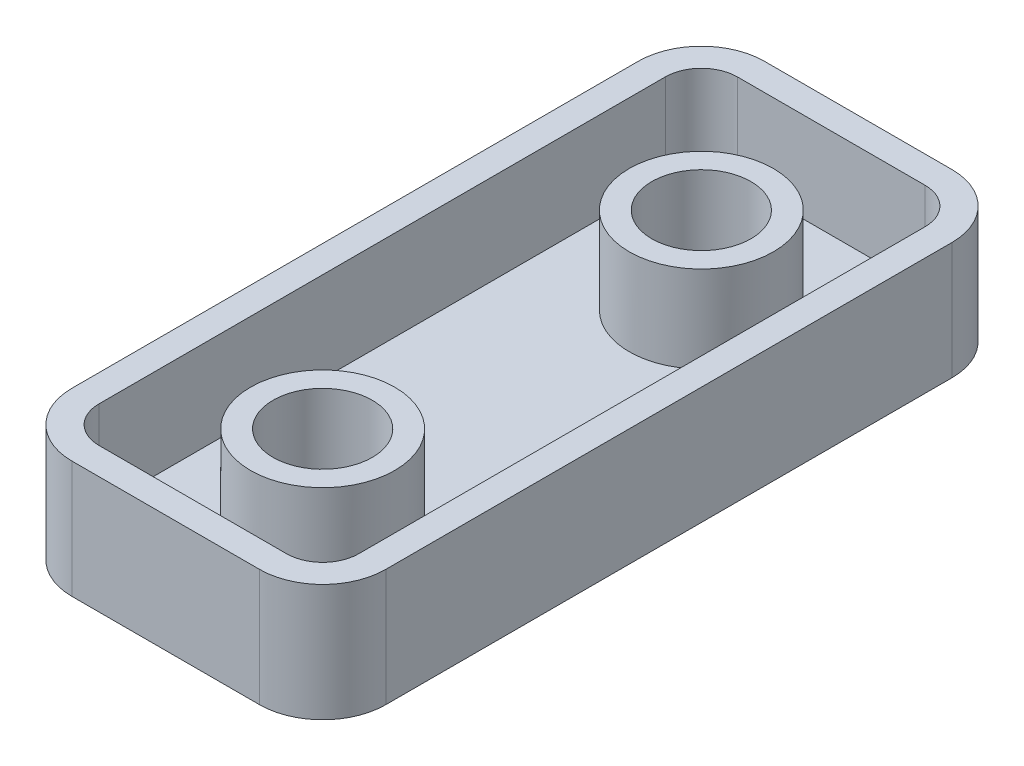
from build123d import *

# Parameters (mm, degrees)
SKETCH1_W           = 17.4
SKETCH1_H           = 38.4
BOSS_EXTRUDE1_DEPTH = 6.5
FILLET1_R           = 3.5
CUT_EXTRUDE1_DEPTH  = 5
SKETCH3_R           = 4
SKETCH3_R_2         = 2.75
BOSS_EXTRUDE2_DEPTH = 4.8
SKETCH4_R           = 2.75
CUT_EXTRUDE2_DEPTH  = 0.9


with BuildPart() as part:
    # Sketch1 → Boss-Extrude1 (new body)
    with BuildSketch(Plane(origin=(0, 0, 0), x_dir=(1, 0, 0), z_dir=(0, 1, 0))):
        with Locations((-8.7, -19.2)):
            Rectangle(SKETCH1_W, SKETCH1_H)
    extrude(amount=BOSS_EXTRUDE1_DEPTH)

    # Fillet1
    fillet1_edges = [part.edges().sort_by_distance(p)[0] for p in [
        (0, 3.25, 38.4),
        (-17.4, 3.25, 38.4),
        (-17.4, 3.25, 0),
        (0, 3.25, 0),
    ]]
    fillet(fillet1_edges, radius=FILLET1_R)

    # Sketch2 → Cut-Extrude1 (cut)
    with BuildSketch(Plane(origin=(0, 6.5, 0), x_dir=(1, 0, 0), z_dir=(0, 1, 0))):
        with BuildLine():
            Line((-13.9, -36.9), (-3.5, -36.9))
            ThreePointArc((-3.5, -36.9), (-2.085786438, -36.314213562), (-1.5, -34.9))
            Line((-1.5, -34.9), (-1.5, -3.5))
            ThreePointArc((-1.5, -3.5), (-2.085786438, -2.085786438), (-3.5, -1.5))
            Line((-3.5, -1.5), (-13.9, -1.5))
            ThreePointArc((-13.9, -1.5), (-15.314213562, -2.085786438), (-15.9, -3.5))
            Line((-15.9, -3.5), (-15.9, -34.9))
            ThreePointArc((-15.9, -34.9), (-15.314213562, -36.314213562), (-13.9, -36.9))
        make_face()
    extrude(amount=-CUT_EXTRUDE1_DEPTH, mode=Mode.SUBTRACT)

    # Sketch3 → Boss-Extrude2 (add)
    with BuildSketch(Plane(origin=(0, 1.5, 0), x_dir=(1, 0, 0), z_dir=(0, 1, 0))):
        with Locations((-8.7, -29.7)):
            Circle(SKETCH3_R)
        with Locations((-8.7, -29.7)):
            Circle(SKETCH3_R_2, mode=Mode.SUBTRACT)
        with Locations((-8.7, -8.7)):
            Circle(SKETCH3_R)
        with Locations((-8.7, -8.7)):
            Circle(SKETCH3_R_2, mode=Mode.SUBTRACT)
    extrude(amount=BOSS_EXTRUDE2_DEPTH)

    # Sketch4 → Cut-Extrude2 (cut)
    with BuildSketch(Plane(origin=(0, 1.5, 0), x_dir=(1, 0, 0), z_dir=(0, 1, 0))):
        with Locations((-8.7, -29.7)):
            Circle(SKETCH4_R)
        with Locations((-8.7, -8.7)):
            Circle(SKETCH4_R)
    extrude(amount=-CUT_EXTRUDE2_DEPTH, mode=Mode.SUBTRACT)


solid = part.part
